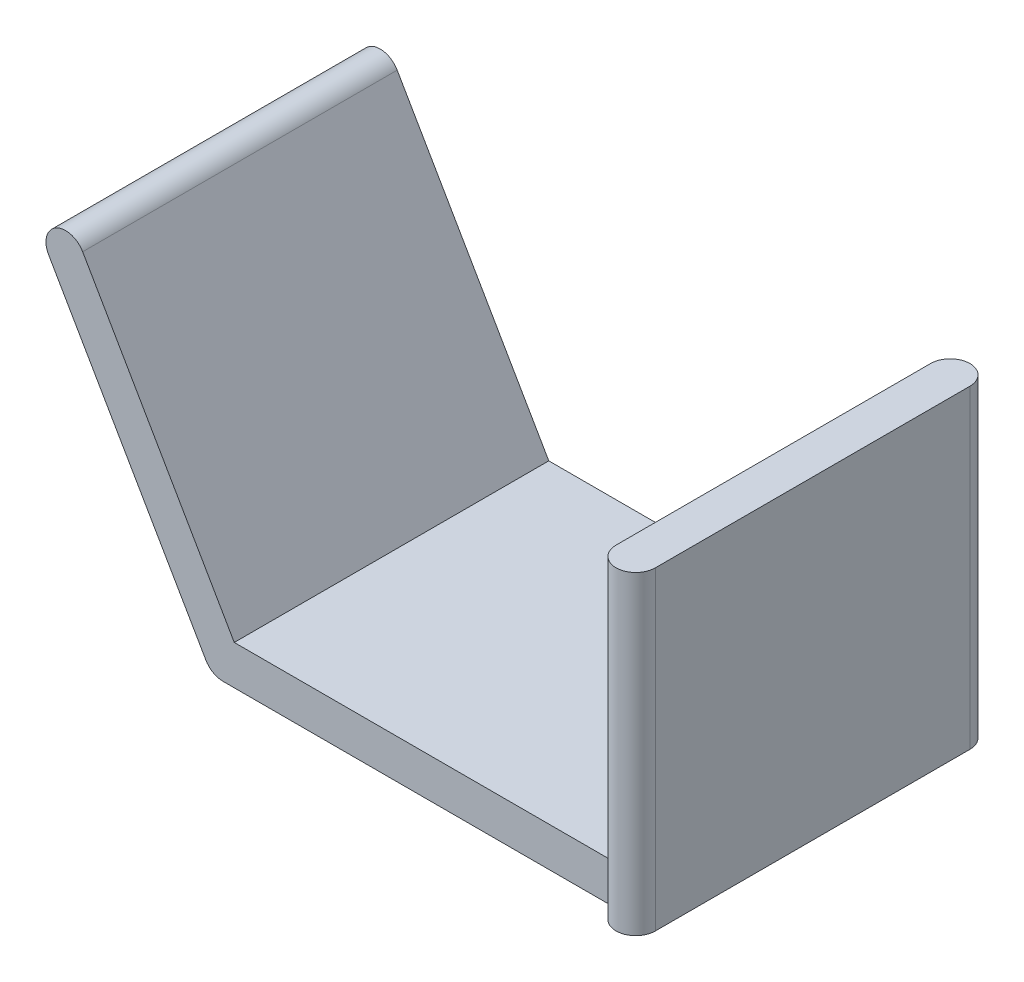
from build123d import *

# Parameters (mm, degrees)
EXTRUDE_9_DEPTH     = 16
SKETCH_12_W         = 3.587626489
SKETCH_12_H         = 2.400728999
CUT_EXTRUDE_2_DEPTH = 16
SKETCH_17_W         = 2
SKETCH_17_H         = 16
EXTRUDE_15_DEPTH    = 16
SKETCH_18_R         = 1
EXTRUDE_16_DEPTH    = 16


with BuildPart() as part:
    # 草图10 → 凸台-拉伸9 (new body)
    with BuildSketch(Plane.XY):
        with BuildLine():
            Line((-8.422649731, 1), (9, 1))
            Line((9, 1), (16.587626489, 1))
            Line((16.587626489, 1), (16.587626489, -1))
            Line((16.587626489, -1), (9, -1))
            Line((9, -1), (-9, -1))
            ThreePointArc((-9, -1), (-9.5, -0.866025404), (-9.866025404, -0.5))
            Line((-9.866025404, -0.5), (-17.866025404, 13.356406461))
            ThreePointArc((-17.866025404, 13.356406461), (-17.5, 14.722431864), (-16.133974596, 14.356406461))
            Line((-16.133974596, 14.356406461), (-8.422649731, 1))
        make_face()
    extrude(amount=EXTRUDE_9_DEPTH)

    # 草图12 → 切除-拉伸2 (cut)
    with BuildSketch(Plane.XY.offset(16)):
        with Locations((14.793813245, -0.2003645)):
            Rectangle(SKETCH_12_W, SKETCH_12_H)
    extrude(amount=-CUT_EXTRUDE_2_DEPTH, mode=Mode.SUBTRACT)

    # 草图17 → 凸台-拉伸15 (add)
    with BuildSketch(Plane.XZ.offset(1)):
        with Locations((12, 8)):
            Rectangle(SKETCH_17_W, SKETCH_17_H)
    extrude(amount=-EXTRUDE_15_DEPTH)

    # 草图18 → 凸台-拉伸16 (add)
    with BuildSketch(Plane(origin=(0, 15, 0), x_dir=(1, 0, 0), z_dir=(0, 1, 0))):
        with Locations((12, 0)):
            Circle(SKETCH_18_R)
        with Locations((12, -16)):
            Circle(SKETCH_18_R)
    extrude(amount=-EXTRUDE_16_DEPTH)


solid = part.part
